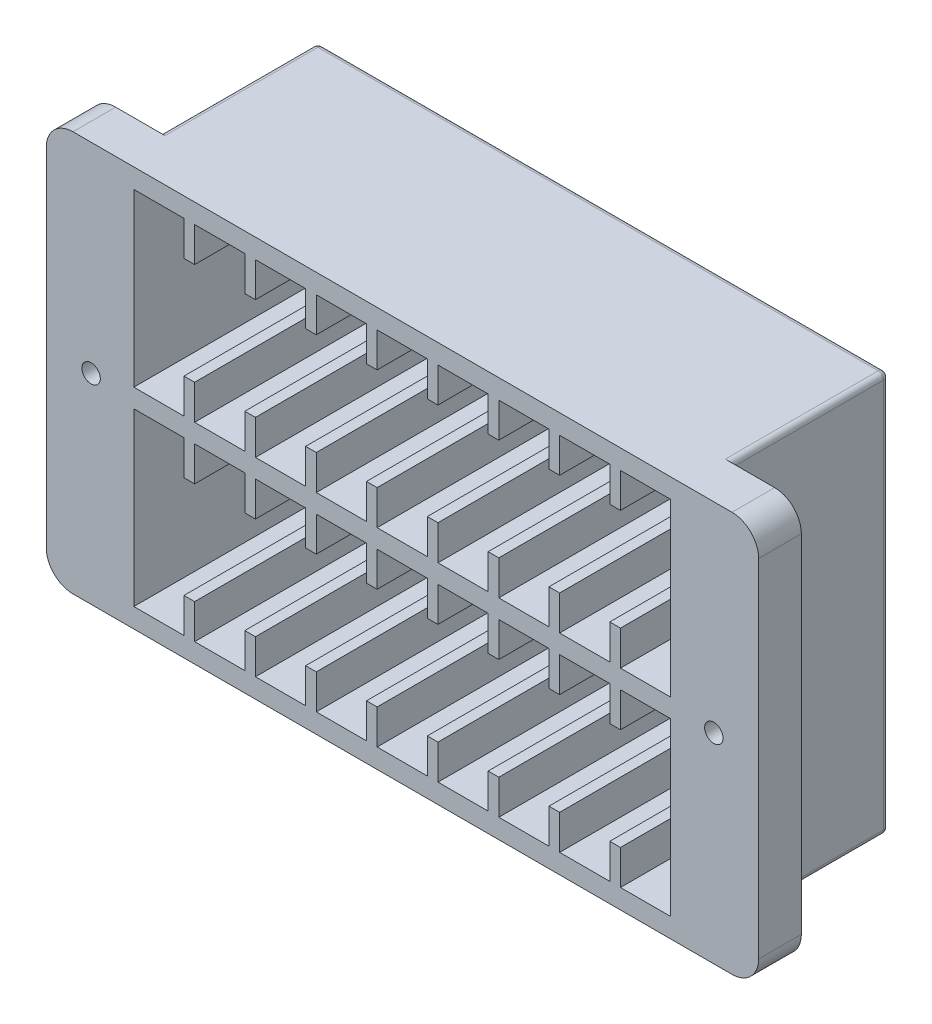
from build123d import *

# Parameters (mm, degrees)
SKETCH1_W           = 133.5
SKETCH1_H           = 75
SKETCH1_R           = 1.725
BOSS_EXTRUDE1_DEPTH = 8
SKETCH2_W           = 107
SKETCH2_H           = 75
BOSS_EXTRUDE2_DEPTH = 29.65
CUT_EXTRUDE1_DEPTH  = 32.65
SKETCH4_W           = 2
SKETCH4_H           = 6.5
BOSS_EXTRUDE3_DEPTH = 32.65
FILLET1_R           = 5
FILLET4_R           = 1


with BuildPart() as part:
    # Sketch1 → Boss-Extrude1 (new body)
    with BuildSketch(Plane.XY):
        Rectangle(SKETCH1_W, SKETCH1_H)
        with Locations((-58.35, 0)):
            Circle(SKETCH1_R, mode=Mode.SUBTRACT)
        with Locations((58.35, 0)):
            Circle(SKETCH1_R, mode=Mode.SUBTRACT)
    extrude(amount=BOSS_EXTRUDE1_DEPTH)

    # Sketch2 → Boss-Extrude2 (add)
    with BuildSketch(Plane(origin=(0, 0, 0), x_dir=(-1, 0, 0), z_dir=(0, 0, -1))):
        Rectangle(SKETCH2_W, SKETCH2_H)
    extrude(amount=BOSS_EXTRUDE2_DEPTH)

    # Sketch3 → Cut-Extrude1 (cut)
    with BuildSketch(Plane.XY.offset(8)):
        Polygon((-38.95, 33.85), (-38.95, 27.35), (-40.95, 27.35), (-40.95, 33.85), (-50.35, 33.85), (-50.35, 1.75), (50.25, 1.75), (50.25, 33.85), (40.85, 33.85), (40.85, 27.35), (38.85, 27.35), (38.85, 33.85), (29.45, 33.85), (29.45, 27.35), (27.45, 27.35), (27.45, 33.85), (18.05, 33.85), (18.05, 27.35), (16.05, 27.35), (16.05, 33.85), (6.65, 33.85), (6.65, 27.35), (4.65, 27.35), (4.65, 33.85), (-4.75, 33.85), (-4.75, 27.35), (-6.75, 27.35), (-6.75, 33.85), (-16.15, 33.85), (-16.15, 27.35), (-18.15, 27.35), (-18.15, 33.85), (-27.55, 33.85), (-27.55, 27.35), (-29.55, 27.35), (-29.55, 33.85), align=None)
    cut_extrude1 = extrude(amount=-CUT_EXTRUDE1_DEPTH, mode=Mode.SUBTRACT)

    # Mirror1: Cut-Extrude1 across plane
    add(cut_extrude1.mirror(Plane.ZX), mode=Mode.SUBTRACT)

    # Sketch4 → Boss-Extrude3 (add)
    with BuildSketch(Plane.XY.offset(8)):
        with Locations((-39.95, 5)):
            Rectangle(SKETCH4_W, SKETCH4_H)
        with Locations((-28.55, 5)):
            Rectangle(SKETCH4_W, SKETCH4_H)
        with Locations((-17.15, 5)):
            Rectangle(SKETCH4_W, SKETCH4_H)
        with Locations((-5.75, 5)):
            Rectangle(SKETCH4_W, SKETCH4_H)
        with Locations((5.65, 5)):
            Rectangle(SKETCH4_W, SKETCH4_H)
        with Locations((17.05, 5)):
            Rectangle(SKETCH4_W, SKETCH4_H)
        with Locations((28.45, 5)):
            Rectangle(SKETCH4_W, SKETCH4_H)
        with Locations((39.85, 5)):
            Rectangle(SKETCH4_W, SKETCH4_H)
    boss_extrude3 = extrude(amount=-BOSS_EXTRUDE3_DEPTH)

    # Mirror2: Boss-Extrude3 across plane
    add(boss_extrude3.mirror(Plane.ZX))

    # Fillet1
    fillet1_edges = [part.edges().sort_by_distance(p)[0] for p in [
        (-66.75, 37.5, 4),
        (66.75, 37.5, 4),
        (66.75, -37.5, 4),
        (-66.75, -37.5, 4),
    ]]
    fillet(fillet1_edges, radius=FILLET1_R)

    # Fillet4
    fillet4_edges = [part.edges().sort_by_distance(p)[0] for p in [
        (53.5, 37.5, -14.825),
        (53.5, -37.5, -14.825),
        (-53.5, -37.5, -14.825),
        (-53.5, 37.5, -14.825),
        (53.5, 0, -29.65),
        (0, -37.5, -29.65),
        (-53.5, 0, -29.65),
        (0, 37.5, -29.65),
    ]]
    fillet(fillet4_edges, radius=FILLET4_R)


solid = part.part
